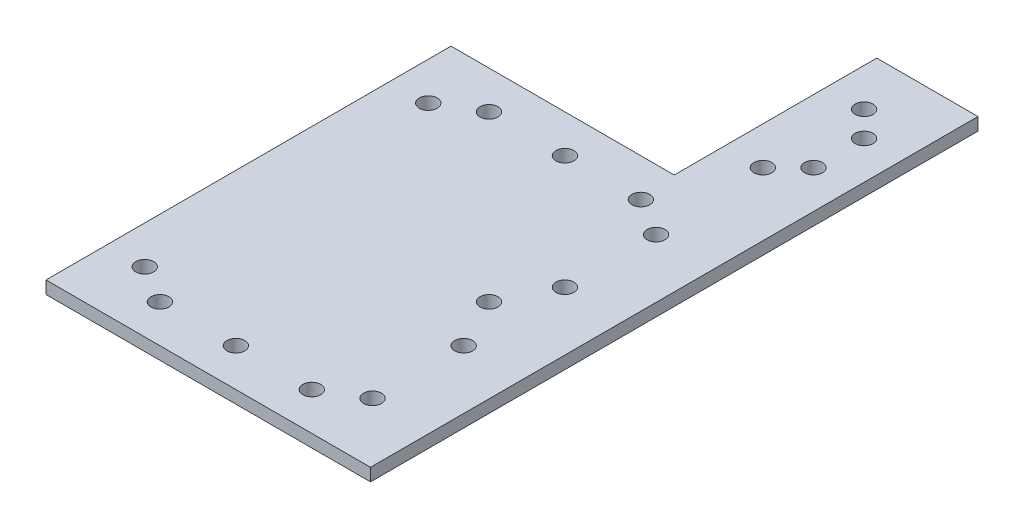
from build123d import *

# Parameters (mm, degrees)
SKETCH1_W           = 76.2
SKETCH1_H           = 101.6
SKETCH1_R           = 2.25
BOSS_EXTRUDE1_DEPTH = 3.175
BOSS_EXTRUDE2_DEPTH = 3.175
SKETCH3_R           = 2.25
CUT_EXTRUDE1_DEPTH  = 10


with BuildPart() as part:
    # Sketch1 → Boss-Extrude1 (new body)
    with BuildSketch(Plane(origin=(0, 0, 0), x_dir=(1, 0, 0), z_dir=(0, 1, 0))):
        Rectangle(SKETCH1_W, SKETCH1_H)
        with Locations((-19.05, -41.275)):
            Circle(SKETCH1_R, mode=Mode.SUBTRACT)
        with Locations((19.05, -41.275)):
            Circle(SKETCH1_R, mode=Mode.SUBTRACT)
        with Locations((28.575, -35.56)):
            Circle(SKETCH1_R, mode=Mode.SUBTRACT)
        with Locations((-28.575, -35.56)):
            Circle(SKETCH1_R, mode=Mode.SUBTRACT)
        with Locations((28.575, 35.56)):
            Circle(SKETCH1_R, mode=Mode.SUBTRACT)
        with Locations((19.05, 41.275)):
            Circle(SKETCH1_R, mode=Mode.SUBTRACT)
        with Locations((-28.575, 35.56)):
            Circle(SKETCH1_R, mode=Mode.SUBTRACT)
        with Locations((-19.05, 41.275)):
            Circle(SKETCH1_R, mode=Mode.SUBTRACT)
        with Locations((0, -41.275)):
            Circle(SKETCH1_R, mode=Mode.SUBTRACT)
        with Locations((0, 41.275)):
            Circle(SKETCH1_R, mode=Mode.SUBTRACT)
        with Locations((28.575, 12.7)):
            Circle(SKETCH1_R, mode=Mode.SUBTRACT)
        with Locations((28.575, -12.7)):
            Circle(SKETCH1_R, mode=Mode.SUBTRACT)
        with Locations((22.23, 0)):
            Circle(SKETCH1_R, mode=Mode.SUBTRACT)
    extrude(amount=BOSS_EXTRUDE1_DEPTH)

    # Sketch2 → Boss-Extrude2 (add)
    with BuildSketch(Plane(origin=(0, 3.175, 0), x_dir=(1, 0, 0), z_dir=(0, 1, 0))):
        Polygon((38.1, -50.8), (43.3, -50.8), (43.3, 101.6), (17.9, 101.6), (17.9, 50.8), (38.1, 50.8), align=None)
    extrude(amount=-BOSS_EXTRUDE2_DEPTH)

    # Sketch3 → Cut-Extrude1 (cut)
    with BuildSketch(Plane(origin=(0, 3.175, 0), x_dir=(1, 0, 0), z_dir=(0, 1, 0))):
        with Locations((33.77, 82.55)):
            Circle(SKETCH3_R)
        with Locations((33.77, 69.85)):
            Circle(SKETCH3_R)
        with Locations((27.425, 88.9)):
            Circle(SKETCH3_R)
        with Locations((27.425, 63.5)):
            Circle(SKETCH3_R)
    extrude(amount=-CUT_EXTRUDE1_DEPTH, mode=Mode.SUBTRACT)


solid = part.part
